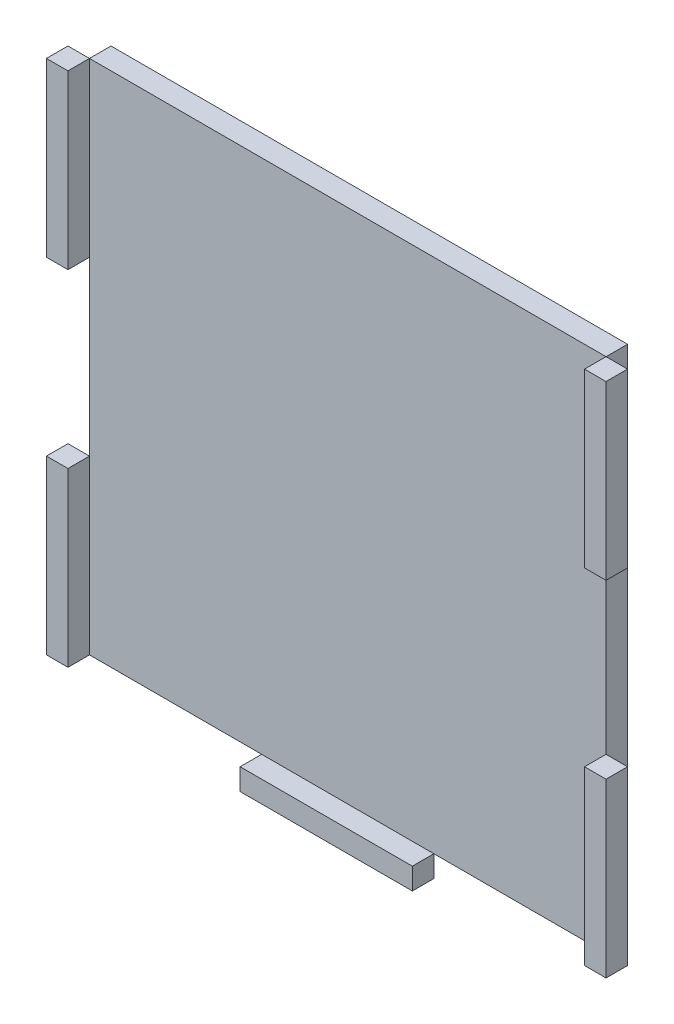
from build123d import *

# Parameters (mm, degrees)
SKETCH2_W             = 76.2
SKETCH2_H             = 76.2
BOSS_EXTRUDE1_DEPTH   = 3.175
SKETCH4_W             = 3.175
SKETCH4_H             = 25.4
BOSS_EXTRUDE2_DEPTH   = 3.175
BOSS_EXTRUDE2_2_DEPTH = 3.175
SKETCH4_W_2           = 25.4
SKETCH4_H_2           = 3.175
BOSS_EXTRUDE2_3_DEPTH = 3.175
BOSS_EXTRUDE2_4_DEPTH = 3.175
BOSS_EXTRUDE2_5_DEPTH = 3.175


with BuildPart() as part:
    # Sketch2 → Boss-Extrude1 (new body)
    with BuildSketch(Plane.XY):
        Rectangle(SKETCH2_W, SKETCH2_H)
    extrude(amount=BOSS_EXTRUDE1_DEPTH)


with BuildPart() as body_2:
    # Sketch4 → Boss-Extrude2 (new body)
    with BuildSketch(Plane.XY.offset(3.175)):
        with Locations((-39.6875, 25.4)):
            Rectangle(SKETCH4_W, SKETCH4_H)
    extrude(amount=BOSS_EXTRUDE2_DEPTH)


with BuildPart() as body_3:
    # Sketch4 → Boss-Extrude2 2 (new body)
    with BuildSketch(Plane.XY.offset(3.175)):
        with Locations((-39.6875, -25.4)):
            Rectangle(SKETCH4_W, SKETCH4_H)
    extrude(amount=BOSS_EXTRUDE2_2_DEPTH)


with BuildPart() as body_4:
    # Sketch4 → Boss-Extrude2 3 (new body)
    with BuildSketch(Plane.XY.offset(3.175)):
        with Locations((0, -39.6875)):
            Rectangle(SKETCH4_W_2, SKETCH4_H_2)
    extrude(amount=BOSS_EXTRUDE2_3_DEPTH)


with BuildPart() as body_5:
    # Sketch4 → Boss-Extrude2 4 (new body)
    with BuildSketch(Plane.XY.offset(3.175)):
        with Locations((39.6875, 25.4)):
            Rectangle(SKETCH4_W, SKETCH4_H)
    extrude(amount=BOSS_EXTRUDE2_4_DEPTH)


with BuildPart() as body_6:
    # Sketch4 → Boss-Extrude2 5 (new body)
    with BuildSketch(Plane.XY.offset(3.175)):
        with Locations((39.6875, -25.4)):
            Rectangle(SKETCH4_W, SKETCH4_H)
    extrude(amount=BOSS_EXTRUDE2_5_DEPTH)


solid = Compound([part.part, body_2.part, body_3.part, body_4.part, body_5.part, body_6.part])
